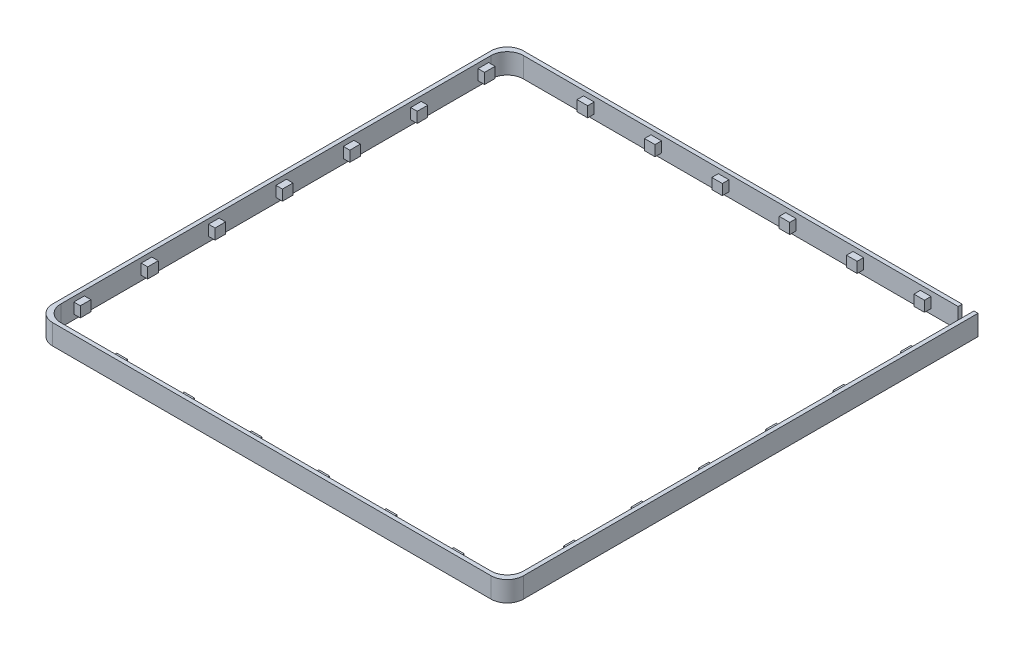
from build123d import *

# Parameters (mm, degrees)
SKETCH_1_W               = 58
SKETCH_1_H               = 58
EXTRUDE_1_DEPTH          = 2.5
SKETCH_2_W               = 57
SKETCH_2_H               = 57
CUT_EXTRUDE_7_DEPTH      = 1
CUT_EXTRUDE_7_DEPTH_BACK = 3.5
SKETCH_5_W               = 1.4427437
SKETCH_5_H               = 2.5
CUT_EXTRUDE_8_DEPTH      = 1.5
SKETCH_6_W               = 1.3
SKETCH_6_H               = 1.3
EXTRUDE_5_DEPTH          = 0.8
FILLET_4_R               = 2
FILLET_5_R               = 2
SKETCH_8_W               = 1.3
SKETCH_8_H               = 1.3
EXTRUDE_6_DEPTH          = 0.8
SKETCH_10_W              = 1.3
SKETCH_10_H              = 1.3
EXTRUDE_8_DEPTH          = 0.8
SKETCH_12_W              = 1.3
SKETCH_12_H              = 1.3
EXTRUDE_9_DEPTH          = 0.8


with BuildPart() as part:
    # 草图1 → 凸台-拉伸1 (new body)
    with BuildSketch(Plane(origin=(0, 0, 0), x_dir=(1, 0, 0), z_dir=(0, 1, 0))):
        Rectangle(SKETCH_1_W, SKETCH_1_H)
    extrude(amount=EXTRUDE_1_DEPTH)

    # 草图2 → 切除-拉伸7 (cut, two sides)
    with BuildSketch(Plane(origin=(0, 2.5, 0), x_dir=(1, 0, 0), z_dir=(0, 1, 0))) as cut_extrude_7_sk:
        Rectangle(SKETCH_2_W, SKETCH_2_H)
    extrude(amount=CUT_EXTRUDE_7_DEPTH, mode=Mode.SUBTRACT)
    extrude(cut_extrude_7_sk.sketch, amount=-CUT_EXTRUDE_7_DEPTH_BACK, mode=Mode.SUBTRACT)

    # 草图5 → 切除-拉伸8 (cut, through all)
    with BuildSketch(Plane.XY.offset(-28.5)):
        with Locations((27.77862815, 1.25)):
            Rectangle(SKETCH_5_W, SKETCH_5_H)
    extrude(amount=-CUT_EXTRUDE_8_DEPTH, mode=Mode.SUBTRACT)

    # 草图6 → 凸台-拉伸5 (add)
    with BuildSketch(Plane.XY.offset(-28.5)):
        with Locations((14.7572563, 1.25)):
            Rectangle(SKETCH_6_W, SKETCH_6_H)
        with Locations((23.0572563, 1.25)):
            Rectangle(SKETCH_6_W, SKETCH_6_H)
        with Locations((6.4572563, 1.25)):
            Rectangle(SKETCH_6_W, SKETCH_6_H)
        with Locations((-1.8427437, 1.25)):
            Rectangle(SKETCH_6_W, SKETCH_6_H)
        with Locations((-10.1427437, 1.25)):
            Rectangle(SKETCH_6_W, SKETCH_6_H)
        with Locations((-18.4427437, 1.25)):
            Rectangle(SKETCH_6_W, SKETCH_6_H)
    extrude(amount=EXTRUDE_5_DEPTH)

    # 圆角4
    fillet_4_edges = [part.edges().sort_by_distance(p)[0] for p in [
        (28.5, 1.25, 28.5),
        (-28.5, 1.25, 28.5),
        (-28.5, 1.25, -28.5),
    ]]
    fillet(fillet_4_edges, radius=FILLET_4_R)

    # 圆角5
    fillet_5_edges = [part.edges().sort_by_distance(p)[0] for p in [
        (29, 1.25, 29),
        (-29, 1.25, 29),
        (-29, 1.25, -29),
    ]]
    fillet(fillet_5_edges, radius=FILLET_5_R)

    # 草图8 → 凸台-拉伸6 (add)
    with BuildSketch(Plane(origin=(-28.5, 0, 0), x_dir=(0, 0, -1), z_dir=(1, 0, 0))):
        with Locations((17.2572563, 1.25)):
            Rectangle(SKETCH_8_W, SKETCH_8_H)
        with Locations((25.5572563, 1.25)):
            Rectangle(SKETCH_8_W, SKETCH_8_H)
        with Locations((8.9572563, 1.25)):
            Rectangle(SKETCH_8_W, SKETCH_8_H)
        with Locations((0.6572563, 1.25)):
            Rectangle(SKETCH_8_W, SKETCH_8_H)
        with Locations((-7.6427437, 1.25)):
            Rectangle(SKETCH_8_W, SKETCH_8_H)
        with Locations((-15.9427437, 1.25)):
            Rectangle(SKETCH_8_W, SKETCH_8_H)
        with Locations((-24.2427437, 1.25)):
            Rectangle(SKETCH_8_W, SKETCH_8_H)
    extrude(amount=EXTRUDE_6_DEPTH)

    # 草图10 → 凸台-拉伸8 (add)
    with BuildSketch(Plane(origin=(0, 0, 28.5), x_dir=(-1, 0, 0), z_dir=(0, 0, -1))):
        with Locations((19.7572563, 1.25)):
            Rectangle(SKETCH_10_W, SKETCH_10_H)
        with Locations((11.4572563, 1.25)):
            Rectangle(SKETCH_10_W, SKETCH_10_H)
        with Locations((3.1572563, 1.25)):
            Rectangle(SKETCH_10_W, SKETCH_10_H)
        with Locations((-5.1427437, 1.25)):
            Rectangle(SKETCH_10_W, SKETCH_10_H)
        with Locations((-13.4427437, 1.25)):
            Rectangle(SKETCH_10_W, SKETCH_10_H)
        with Locations((-21.7427437, 1.25)):
            Rectangle(SKETCH_10_W, SKETCH_10_H)
    extrude(amount=EXTRUDE_8_DEPTH)

    # 草图12 → 凸台-拉伸9 (add)
    with BuildSketch(Plane.ZY.offset(-28.5)):
        with Locations((20.1072563, 1.25)):
            Rectangle(SKETCH_12_W, SKETCH_12_H)
        with Locations((11.8072563, 1.25)):
            Rectangle(SKETCH_12_W, SKETCH_12_H)
        with Locations((3.5072563, 1.25)):
            Rectangle(SKETCH_12_W, SKETCH_12_H)
        with Locations((-4.7927437, 1.25)):
            Rectangle(SKETCH_12_W, SKETCH_12_H)
        with Locations((-13.0927437, 1.25)):
            Rectangle(SKETCH_12_W, SKETCH_12_H)
        with Locations((-21.3927437, 1.25)):
            Rectangle(SKETCH_12_W, SKETCH_12_H)
    extrude(amount=EXTRUDE_9_DEPTH)


solid = part.part
